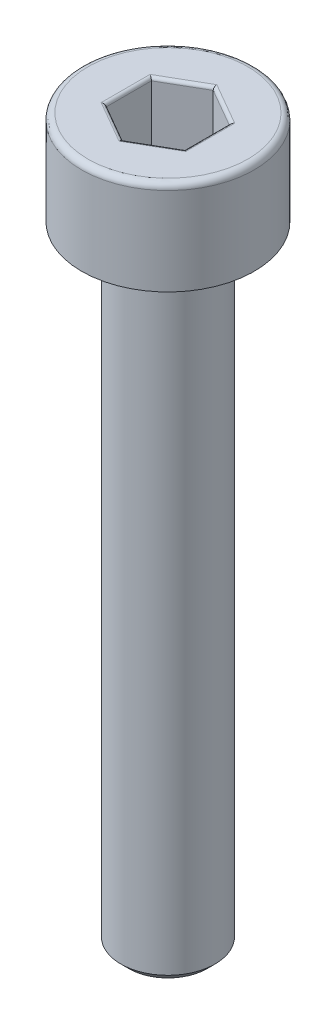
from build123d import *

# Parameters (mm, degrees)
CHAMFER1_SIZE      = 0.25
FILLET1_R          = 0.2
CUT_EXTRUDE1_DEPTH = 2
FILLET2_R          = 0.1


with BuildPart() as part:
    # Sketch1 → Revolve1 (revolve)
    with BuildSketch(Plane.XY):
        Polygon((0, -23), (-1.5, -23), (-1.5, -3), (-2.75, -3), (-2.75, 0), (0, 0), align=None)
    revolve(axis=Axis((0, 0, 0), (0, -1, 0)))

    # Chamfer1
    chamfer1_edges = [part.edges().sort_by_distance(p)[0] for p in [
        (1.5, -3, 0),
        (1.5, -23, 0),
    ]]
    chamfer(chamfer1_edges, length=CHAMFER1_SIZE)

    # Fillet1
    fillet1_edges = [part.edges().sort_by_distance(p)[0] for p in [
        (2.75, 0, 0),
    ]]
    fillet(fillet1_edges, radius=FILLET1_R)

    # Sketch2 → Cut-Extrude1 (cut)
    with BuildSketch(Plane(origin=(0, 0, 0), x_dir=(1, 0, 0), z_dir=(0, 1, 0))):
        Polygon((0, 1.443375673), (-1.25, 0.721687836), (-1.25, -0.721687836), (0, -1.443375673), (1.25, -0.721687836), (1.25, 0.721687836), align=None)
    extrude(amount=-CUT_EXTRUDE1_DEPTH, mode=Mode.SUBTRACT)

    # Fillet2
    fillet2_edges = [part.edges().sort_by_distance(p)[0] for p in [
        (0.625, -2, -1.082531755),
        (1.25, -2, 0),
        (0.625, -2, 1.082531755),
        (-0.625, -2, 1.082531755),
        (-1.25, -2, 0),
        (-0.625, -2, -1.082531755),
        (0.625, 0, -1.082531755),
        (-0.625, 0, -1.082531755),
        (-1.25, 0, 0),
        (-0.625, 0, 1.082531755),
        (0.625, 0, 1.082531755),
        (1.25, 0, 0),
    ]]
    fillet(fillet2_edges, radius=FILLET2_R)


solid = part.part
